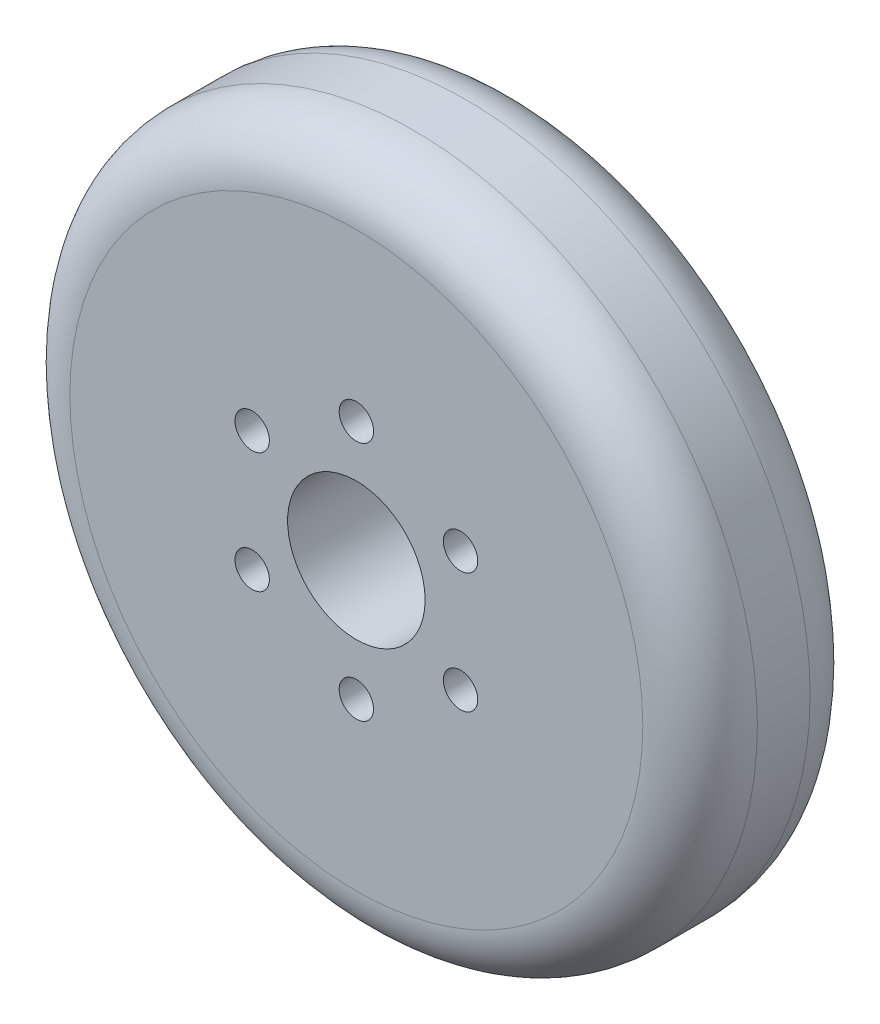
from build123d import *

# Parameters (mm, degrees)
SKETCH_1_R               = 30
SKETCH_1_R_2             = 6
EXTRUDE_1_DEPTH          = 14.6
FILLET_2_R               = 5
SKETCH_3_R               = 1.5
CUT_EXTRUDE_1_DEPTH      = 15.6
PATTERN_CIRCULAR_2_COUNT = 6


with BuildPart() as part:
    # ｽｹｯﾁ1 → ﾎﾞｽ - 押し出し1 (new body)
    with BuildSketch(Plane.XY):
        Circle(SKETCH_1_R)
        Circle(SKETCH_1_R_2, mode=Mode.SUBTRACT)
    extrude(amount=EXTRUDE_1_DEPTH)

    # ﾌｨﾚｯﾄ2
    fillet_2_edges = [part.edges().sort_by_distance(p)[0] for p in [
        (-30, 0, 0),
        (-30, 0, 14.6),
    ]]
    fillet(fillet_2_edges, radius=FILLET_2_R)

    # ｽｹｯﾁ3 → ｶｯﾄ - 押し出し1 (cut, through all)
    with BuildSketch(Plane(origin=(0, 0, 0), x_dir=(-1, 0, 0), z_dir=(0, 0, -1))):
        with Locations((0, 10.5)):
            Circle(SKETCH_3_R)
    cut_extrude_1 = extrude(amount=-CUT_EXTRUDE_1_DEPTH, mode=Mode.SUBTRACT)

    # 円形ﾊﾟﾀｰﾝ2: ｶｯﾄ - 押し出し1 ×6 about axis
    pattern_circular_2_axis = Axis((0, 0, 0), (0, 0, 1))
    for i in range(1, PATTERN_CIRCULAR_2_COUNT):
        add(cut_extrude_1.rotate(pattern_circular_2_axis, i * 360 / PATTERN_CIRCULAR_2_COUNT), mode=Mode.SUBTRACT)


solid = part.part
